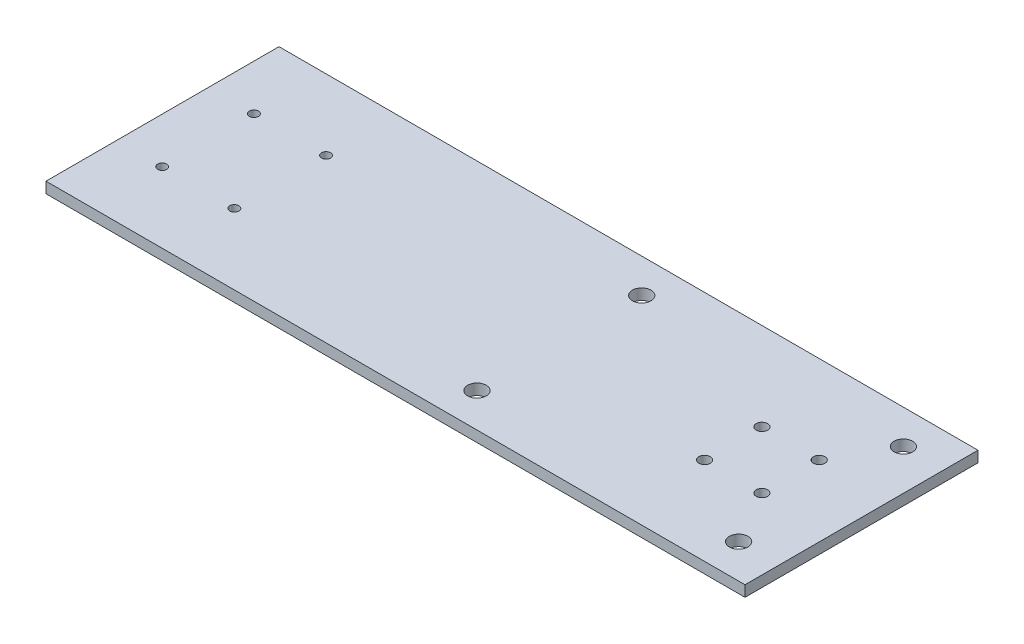
from build123d import *

# Parameters (mm, degrees)
SKETCH2_W           = 304.8
SKETCH2_H           = 101.6
SKETCH2_R           = 2.5
SKETCH2_R_2         = 4.05
SKETCH2_R_3         = 2
BOSS_EXTRUDE1_DEPTH = 4.7625


with BuildPart() as part:
    # Sketch2 → Boss-Extrude1 (new body)
    with BuildSketch(Plane(origin=(0, 0, 0), x_dir=(1, 0, 0), z_dir=(0, 1, 0))):
        with Locations((152.4, 76.2)):
            Rectangle(SKETCH2_W, SKETCH2_H)
        with Locations((248.864414399, 88.7)):
            Circle(SKETCH2_R, mode=Mode.SUBTRACT)
        with Locations((248.864414399, 63.7)):
            Circle(SKETCH2_R, mode=Mode.SUBTRACT)
        with Locations((273.864414399, 63.7)):
            Circle(SKETCH2_R, mode=Mode.SUBTRACT)
        with Locations((273.864414399, 88.7)):
            Circle(SKETCH2_R, mode=Mode.SUBTRACT)
        with Locations((173.042404906, 40.2828125)):
            Circle(SKETCH2_R_2, mode=Mode.SUBTRACT)
        with Locations((173.042404906, 112.1171875)):
            Circle(SKETCH2_R_2, mode=Mode.SUBTRACT)
        with Locations((287.14304819, 40.2828125)):
            Circle(SKETCH2_R_2, mode=Mode.SUBTRACT)
        with Locations((287.14304819, 112.1171875)):
            Circle(SKETCH2_R_2, mode=Mode.SUBTRACT)
        with Locations((19.876076597, 56.20004)):
            Circle(SKETCH2_R_3, mode=Mode.SUBTRACT)
        with Locations((51.328800148, 56.20004)):
            Circle(SKETCH2_R_3, mode=Mode.SUBTRACT)
        with Locations((51.328800148, 96.19996)):
            Circle(SKETCH2_R_3, mode=Mode.SUBTRACT)
        with Locations((19.876076597, 96.19996)):
            Circle(SKETCH2_R_3, mode=Mode.SUBTRACT)
    extrude(amount=BOSS_EXTRUDE1_DEPTH)


solid = part.part
